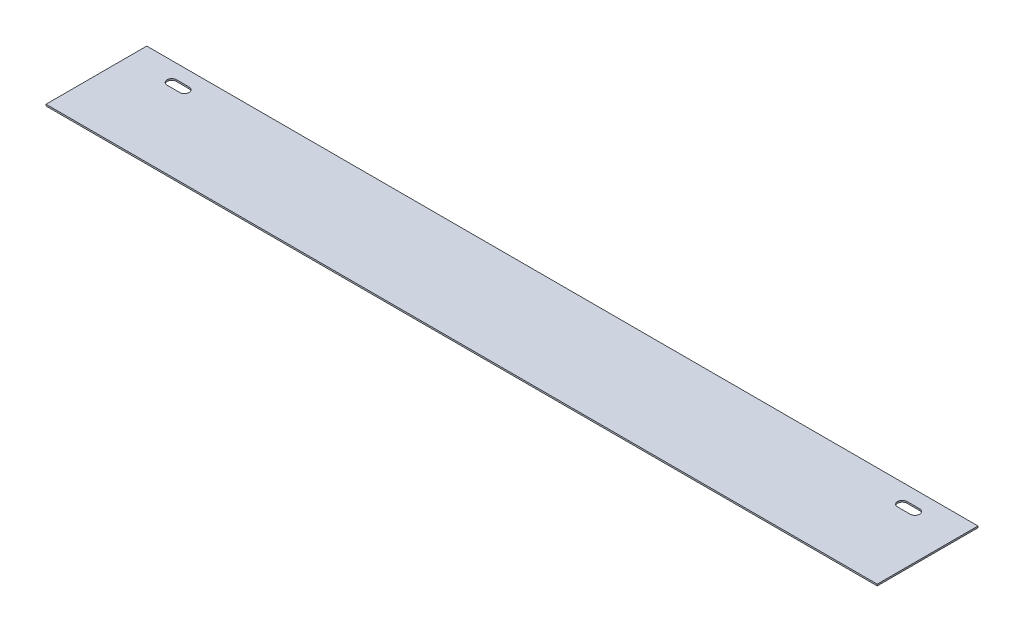
from build123d import *

# Parameters (mm, degrees)
SKETCH1_W           = 838.2
SKETCH1_H           = 101.6
BOSS_EXTRUDE1_DEPTH = 1.6002
CUT_EXTRUDE1_DEPTH  = 2.6002


with BuildPart() as part:
    # Sketch1 → Boss-Extrude1 (new body)
    with BuildSketch(Plane(origin=(0, 0, 0), x_dir=(1, 0, 0), z_dir=(0, 1, 0))):
        with Locations((419.1, -50.8)):
            Rectangle(SKETCH1_W, SKETCH1_H)
    extrude(amount=BOSS_EXTRUDE1_DEPTH)

    # Sketch2 → Cut-Extrude1 (cut, through all)
    with BuildSketch(Plane(origin=(0, 1.6002, 0), x_dir=(1, 0, 0), z_dir=(0, 1, 0))):
        with BuildLine():
            Line((44.45, -14.4145), (57.15, -14.4145))
            ThreePointArc((57.15, -14.4145), (61.9125, -19.177), (57.15, -23.9395))
            Line((57.15, -23.9395), (44.45, -23.9395))
            ThreePointArc((44.45, -23.9395), (39.6875, -19.177), (44.45, -14.4145))
        make_face()
        with BuildLine():
            Line((781.05, -14.4145), (793.75, -14.4145))
            ThreePointArc((793.75, -14.4145), (798.5125, -19.177), (793.75, -23.9395))
            Line((793.75, -23.9395), (781.05, -23.9395))
            ThreePointArc((781.05, -23.9395), (776.2875, -19.177), (781.05, -14.4145))
        make_face()
    extrude(amount=-CUT_EXTRUDE1_DEPTH, mode=Mode.SUBTRACT)


solid = part.part
